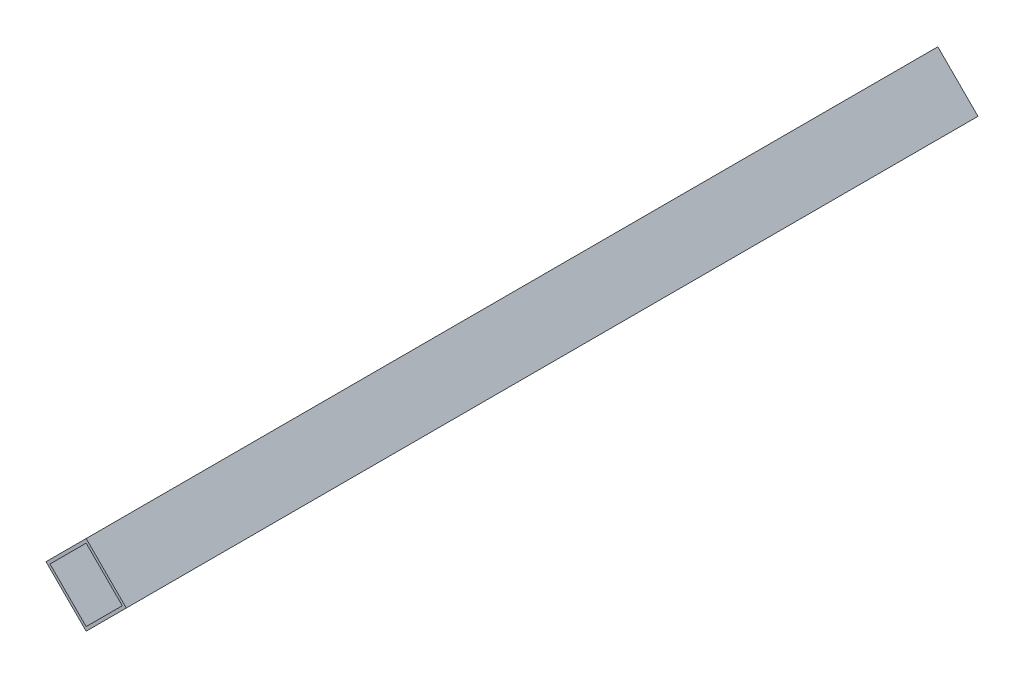
from build123d import *

# Parameters (mm, degrees)
EXTRUDE_1_DEPTH     = 300
SKETCH_2_R          = 1
CUT_EXTRUDE_1_DEPTH = 31


with BuildPart() as part:
    # 草图1 → 凸台-拉伸1 (new body)
    with BuildSketch(Plane.XY):
        Polygon((14.142135624, 0), (0, 14.142135624), (-14.142135624, 0), (0, -14.142135624), align=None)
        Polygon((12.727922061, 0), (0, 12.727922061), (-12.727922061, 0), (0, -12.727922061), align=None, mode=Mode.SUBTRACT)
    extrude(amount=EXTRUDE_1_DEPTH)

    # 草图2 → 切除-拉伸1 (cut, through all)
    with BuildSketch(Plane(origin=(7.071067812, -7.071067812, 0), x_dir=(0, 0, -1), z_dir=(0.707106781, -0.707106781, 0))):
        with Locations((-290, 0)):
            Circle(SKETCH_2_R)
        with Locations((-220, 0)):
            Circle(SKETCH_2_R)
        with Locations((-150, 0)):
            Circle(SKETCH_2_R)
        with Locations((-80, 0)):
            Circle(SKETCH_2_R)
        with Locations((-10, 0)):
            Circle(SKETCH_2_R)
    extrude(amount=-CUT_EXTRUDE_1_DEPTH, mode=Mode.SUBTRACT)


solid = part.part
